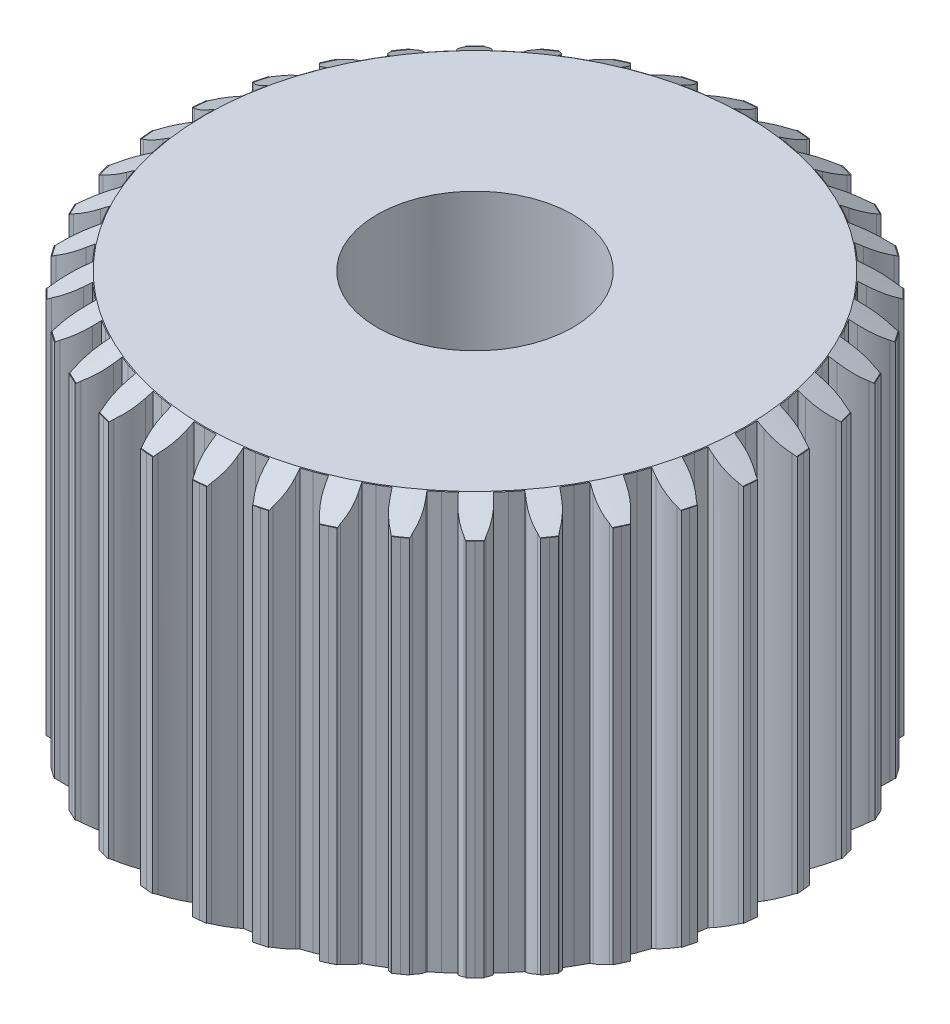
from build123d import *

# Parameters (mm, degrees)
BOSS_EXTRUDE1_DEPTH = 3.2
CIRPATTERN1_COUNT   = 36
SKETCH2_R           = 0.75
CUT_EXTRUDE1_DEPTH  = 1
SKETCH4_R           = 0.75
CUT_EXTRUDE2_DEPTH  = 3.2


with BuildPart() as part:
    # Sketch1 → Boss-Extrude1 (new body)
    with BuildSketch(Plane(origin=(0, 0, 0), x_dir=(1, 0, 0), z_dir=(0, 1, 0))):
        with BuildLine():
            Line((2.075, 0), (0, 0))
            Line((0, 0), (2.043476088, 0.360319969))
            Line((2.043476088, 0.360319969), (2.055822905, 0.281455474))
            Line((2.055822905, 0.281455474), (2.10563264, 0.285813261))
            ThreePointArc((2.10563264, 0.285813261), (2.194949244, 0.283215186), (2.281259549, 0.260090808))
            Line((2.281259549, 0.260090808), (2.311259549, 0.252397099))
            Line((2.311259549, 0.252397099), (2.316152673, 0.202637102))
            Line((2.316152673, 0.202637102), (2.31997462, 0.152783389))
            Line((2.31997462, 0.152783389), (2.291766386, 0.13999712))
            ThreePointArc((2.291766386, 0.13999712), (2.210123969, 0.106613051), (2.12302506, 0.092693276))
            Line((2.12302506, 0.092693276), (2.07302506, 0.090510229))
            Line((2.07302506, 0.090510229), (2.075, 0))
        make_face()
    boss_extrude1 = extrude(amount=BOSS_EXTRUDE1_DEPTH)

    # CirPattern1: Boss-Extrude1 ×36 about axis
    cirpattern1_axis = Axis((0, 0, 0), (0, 1, 0))
    for i in range(1, CIRPATTERN1_COUNT):
        add(boss_extrude1.rotate(cirpattern1_axis, i * 360 / CIRPATTERN1_COUNT))

    # Sketch2 → Cut-Extrude1 (cut)
    with BuildSketch(Plane.XZ):
        Circle(SKETCH2_R)
    extrude(amount=-CUT_EXTRUDE1_DEPTH, mode=Mode.SUBTRACT)

    # Sketch3 → Cut-Revolve1 (revolve, cut)
    with BuildSketch(Plane.XY):
        Polygon((-2.36997462, 0.15), (-2.31997462, 0.15), (-2.06997462, 0), (-2.36997462, 0), align=None)
        Polygon((-2.31997462, 3.05), (-2.06997462, 3.2), (-2.36997462, 3.2), (-2.36997462, 3.05), align=None)
    revolve(axis=Axis((0, 0, 0), (0, 1, 0)), mode=Mode.SUBTRACT)

    # Sketch4 → Cut-Extrude2 (cut)
    with BuildSketch(Plane(origin=(0, 3.2, 0), x_dir=(1, 0, 0), z_dir=(0, 1, 0))):
        Circle(SKETCH4_R)
    extrude(amount=-CUT_EXTRUDE2_DEPTH, mode=Mode.SUBTRACT)


solid = part.part
